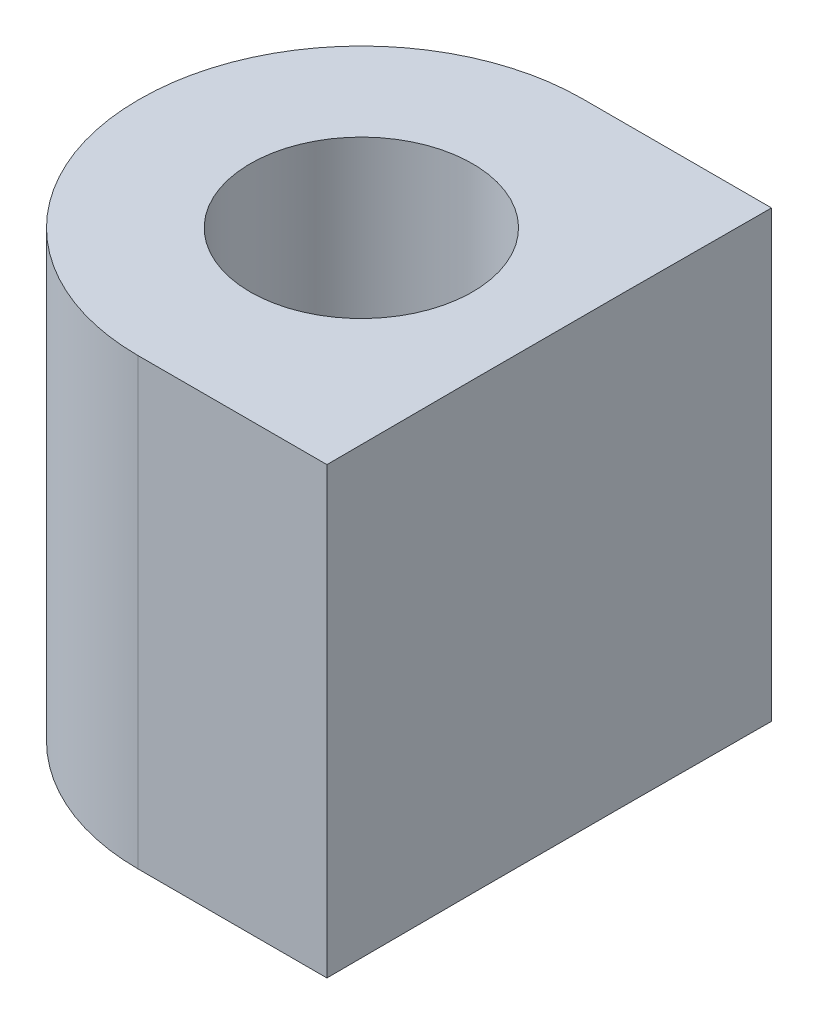
from build123d import *

# Parameters (mm, degrees)
SKETCH1_R           = 3.175
BOSS_EXTRUDE1_DEPTH = 12.7


with BuildPart() as part:
    # Sketch1 → Boss-Extrude1 (new body)
    with BuildSketch(Plane(origin=(0, 0, 0), x_dir=(1, 0, 0), z_dir=(0, 1, 0))):
        with BuildLine():
            Line((-0.0254, -6.35), (5.366129104, -6.35))
            ThreePointArc((5.366129104, -6.35), (5.35, 0), (5.366129104, 6.35))
            Line((5.366129104, 6.35), (-0.0254, 6.35))
            ThreePointArc((-0.0254, 6.35), (-4.497567548, 4.497567548), (-6.35, 0.0254))
            Line((-6.35, 0.0254), (-6.35, -0.0254))
            ThreePointArc((-6.35, -0.0254), (-4.497567548, -4.497567548), (-0.0254, -6.35))
        make_face()
        Circle(SKETCH1_R, mode=Mode.SUBTRACT)
    extrude(amount=BOSS_EXTRUDE1_DEPTH)


solid = part.part
